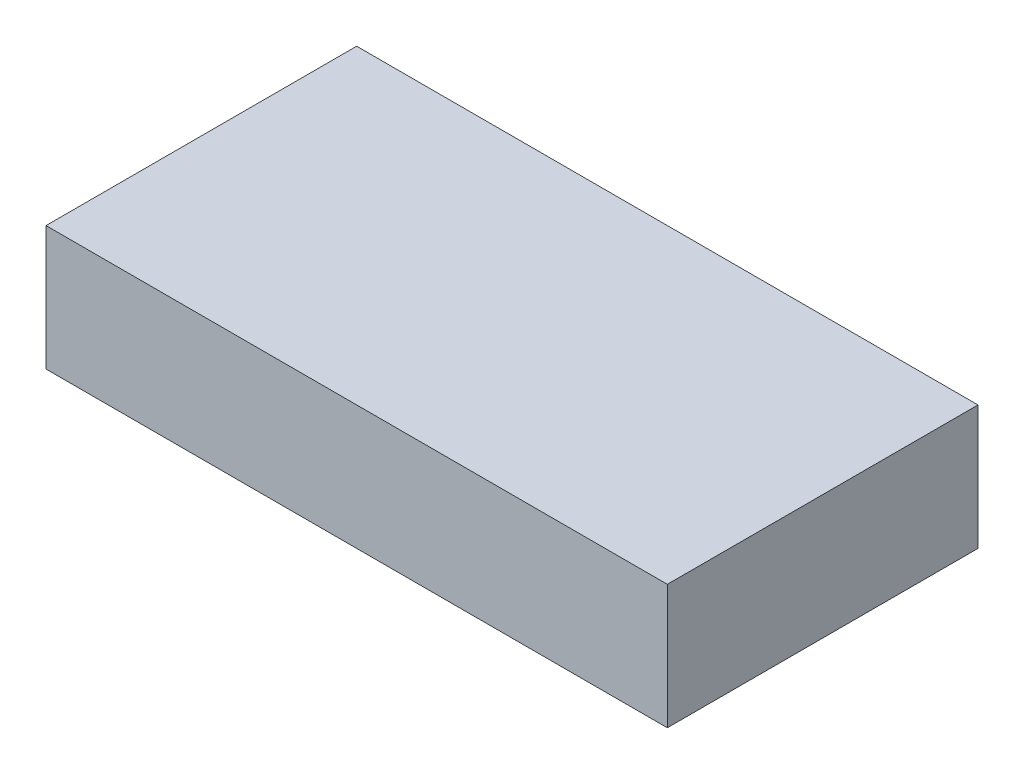
from build123d import *

# Parameters (mm, degrees)
SKETCH1_W           = 200
SKETCH1_H           = 100
BOSS_EXTRUDE1_DEPTH = 40


with BuildPart() as part:
    # Sketch1 → Boss-Extrude1 (new body)
    with BuildSketch(Plane(origin=(0, 0, 0), x_dir=(1, 0, 0), z_dir=(0, 1, 0))):
        with Locations((35.087935014, 20.869380672)):
            Rectangle(SKETCH1_W, SKETCH1_H)
    extrude(amount=BOSS_EXTRUDE1_DEPTH)


solid = part.part
